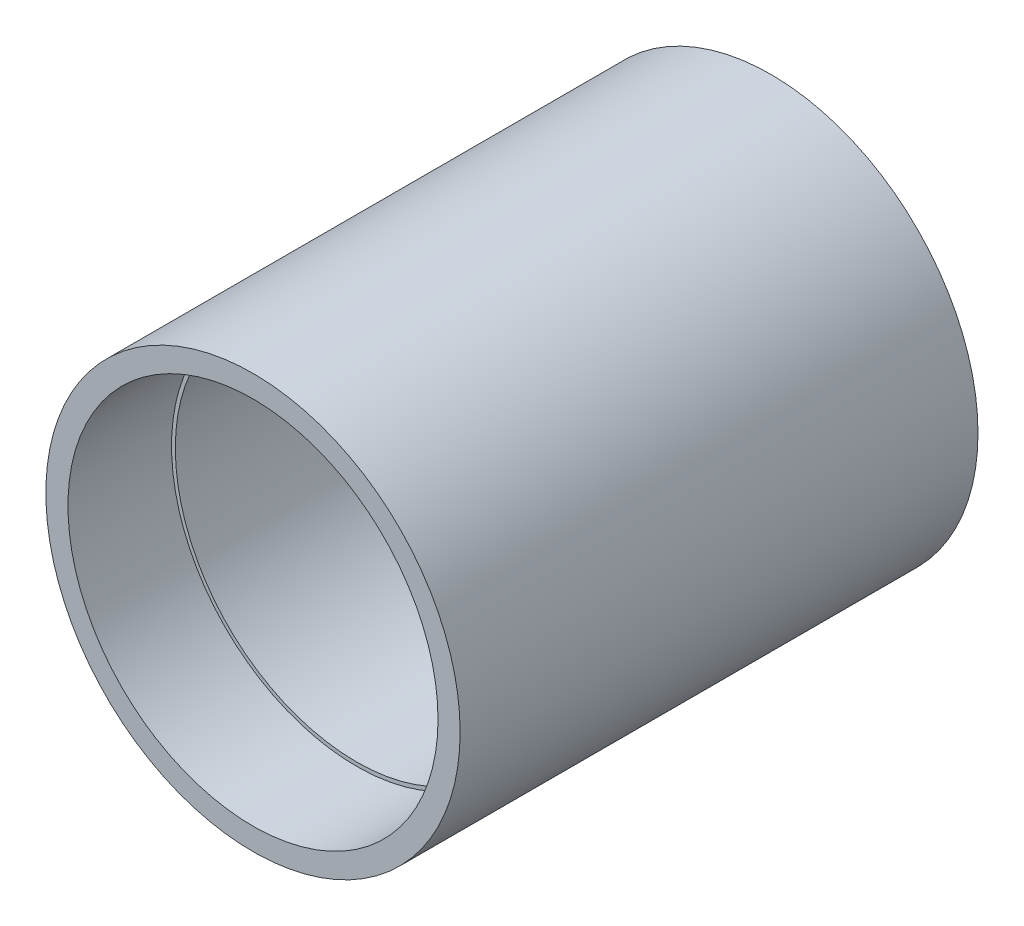
from build123d import *

# Parameters (mm, degrees)
SKIZZE1_R                       = 40
SKIZZE1_R_2                     = 35
AUFSATZ_LINEAR_AUSTRAGEN1_DEPTH = 100
SKIZZE4_R                       = 35.73
SCHNITT_LINEAR_AUSTRAGEN1_DEPTH = 20


with BuildPart() as part:
    # Skizze1 → Aufsatz-Linear austragen1 (new body)
    with BuildSketch(Plane.XY):
        Circle(SKIZZE1_R)
        Circle(SKIZZE1_R_2, mode=Mode.SUBTRACT)
    extrude(amount=AUFSATZ_LINEAR_AUSTRAGEN1_DEPTH)

    # Skizze4 → Schnitt-Linear austragen1 (cut)
    with BuildSketch(Plane.XY.offset(100)):
        Circle(SKIZZE4_R)
    extrude(amount=-SCHNITT_LINEAR_AUSTRAGEN1_DEPTH, mode=Mode.SUBTRACT)


solid = part.part
